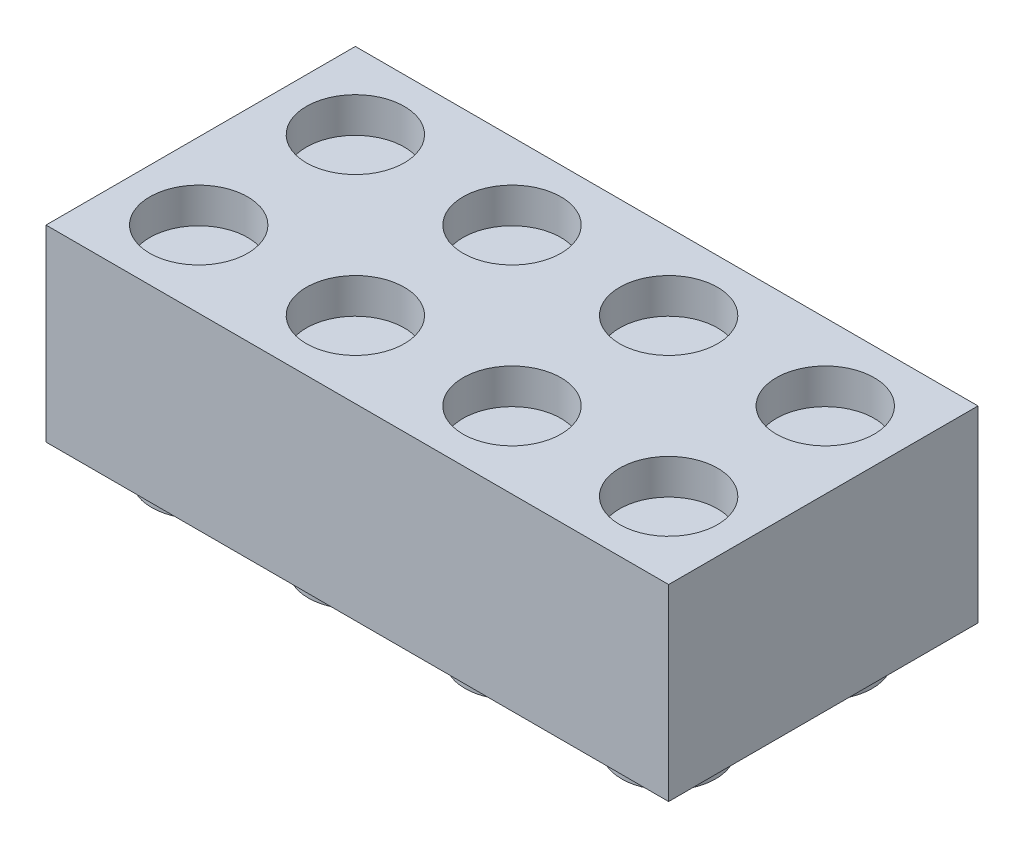
from build123d import *

# Parameters (mm, degrees)
SKETCH_1_W          = 31.8
SKETCH_1_H          = 15.8
EXTRUDE_1_DEPTH     = 9.6
SKETCH_2_R          = 2.4
EXTRUDE_4_DEPTH     = 1.7
SKETCH_3_R          = 2.5
CUT_EXTRUDE_1_DEPTH = 1.8


with BuildPart() as part:
    # Эскиз1 → Бобышка-Вытянуть1 (new body)
    with BuildSketch(Plane(origin=(0, 0, 0), x_dir=(1, 0, 0), z_dir=(0, 1, 0))):
        with Locations((15.9, 7.9)):
            Rectangle(SKETCH_1_W, SKETCH_1_H)
    extrude(amount=EXTRUDE_1_DEPTH)

    # Эскиз2 → Бобышка-Вытянуть4 (add)
    with BuildSketch(Plane.XZ):
        with Locations((27.9, -3.9)):
            Circle(SKETCH_2_R)
        with Locations((19.9, -3.9)):
            Circle(SKETCH_2_R)
        with Locations((11.9, -3.9)):
            Circle(SKETCH_2_R)
        with Locations((3.9, -3.9)):
            Circle(SKETCH_2_R)
        with Locations((19.9, -11.9)):
            Circle(SKETCH_2_R)
        with Locations((11.9, -11.9)):
            Circle(SKETCH_2_R)
        with Locations((3.9, -11.9)):
            Circle(SKETCH_2_R)
        with Locations((27.9, -11.9)):
            Circle(SKETCH_2_R)
    extrude(amount=EXTRUDE_4_DEPTH)

    # Эскиз3 → Вырез-Вытянуть1 (cut)
    with BuildSketch(Plane(origin=(0, 9.6, 0), x_dir=(1, 0, 0), z_dir=(0, 1, 0))):
        with Locations((27.9, 3.9)):
            Circle(SKETCH_3_R)
        with Locations((19.9, 3.9)):
            Circle(SKETCH_3_R)
        with Locations((11.9, 3.9)):
            Circle(SKETCH_3_R)
        with Locations((3.9, 3.9)):
            Circle(SKETCH_3_R)
        with Locations((19.9, 11.9)):
            Circle(SKETCH_3_R)
        with Locations((11.9, 11.9)):
            Circle(SKETCH_3_R)
        with Locations((3.9, 11.9)):
            Circle(SKETCH_3_R)
        with Locations((27.9, 11.9)):
            Circle(SKETCH_3_R)
    extrude(amount=-CUT_EXTRUDE_1_DEPTH, mode=Mode.SUBTRACT)


solid = part.part
